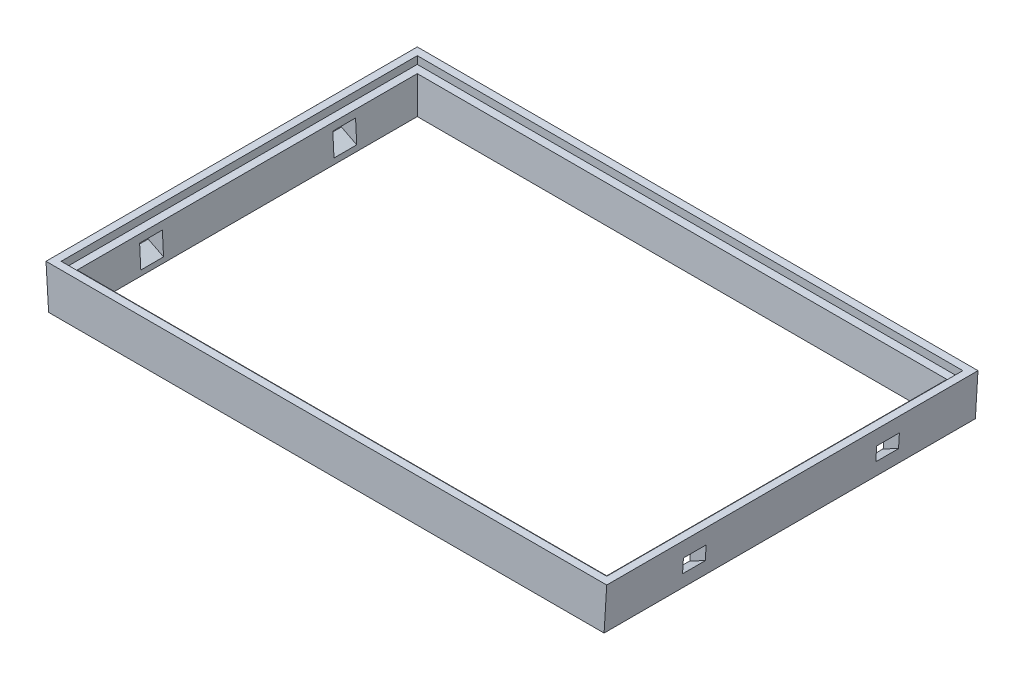
from build123d import *

# Parameters (mm, degrees)
EXTRUDE_1_DEPTH          = 49
SKETCH_2_W               = 70
SKETCH_2_H               = 45
CUT_EXTRUDE_1_DEPTH      = 55.224494
CUT_EXTRUDE_1_TAPER      = 3
SKETCH_3_W               = 72
SKETCH_3_H               = 47
CUT_EXTRUDE_2_DEPTH      = 1
SKETCH_5_W               = 3
SKETCH_5_H               = 3
CUT_EXTRUDE_3_DEPTH      = 2
EXTRUDE_2_DEPTH          = 3
EXTRUDE_3_DEPTH          = 3
SKETCH_9_W               = 92.207980396
SKETCH_9_H               = 62.219536403
CUT_EXTRUDE_4_DEPTH      = 20
CUT_EXTRUDE_4_DEPTH_BACK = 32.556614873


with BuildPart() as part:
    # Sketch 1 → Extrude 1 (new body)
    with BuildSketch(Plane.XY):
        Polygon((16.715993843, 25.667879294), (20.215993843, -31.556614873), (87.215993843, -31.556614873), (90.715993843, 25.667879294), align=None)
    extrude(amount=EXTRUDE_1_DEPTH)

    # Sketch 2 → Cut-Extrude 1 (cut)
    with BuildSketch(Plane(origin=(0, 25.667879294, 0), x_dir=(1, 0, 0), z_dir=(0, 1, 0))):
        with Locations((53.715993843, -24.5)):
            Rectangle(SKETCH_2_W, SKETCH_2_H)
    extrude(amount=-CUT_EXTRUDE_1_DEPTH, taper=CUT_EXTRUDE_1_TAPER, mode=Mode.SUBTRACT)

    # Sketch 3 → Cut-Extrude 2 (cut)
    with BuildSketch(Plane(origin=(0, 25.667879294, 0), x_dir=(1, 0, 0), z_dir=(0, 1, 0))):
        with Locations((53.715993843, -24.5)):
            Rectangle(SKETCH_3_W, SKETCH_3_H)
    extrude(amount=-CUT_EXTRUDE_2_DEPTH, mode=Mode.SUBTRACT)

    # Sketch 5 → Cut-Extrude 3 (cut)
    with BuildSketch(Plane(origin=(20.006241746, 1.048482702, 0), x_dir=(0, 0, -1), z_dir=(0.998629535, 0.052335956, 0))):
        with Locations((-37.25, 21.151810576)):
            Rectangle(SKETCH_5_W, SKETCH_5_H)
        with Locations((-11.75, 21.206889344)):
            Rectangle(SKETCH_5_W, SKETCH_5_H)
    cut_extrude_3 = extrude(amount=-CUT_EXTRUDE_3_DEPTH, mode=Mode.SUBTRACT)

    # Sketch 6 → Extrude 2 (add)
    with BuildSketch(Plane.XY.offset(35.75)):
        Polygon((18.977745448, 20.673361155), (16.95854549, 21.70219492), (17.027722258, 20.57116477), align=None)
    extrude_2 = extrude(amount=EXTRUDE_2_DEPTH)

    # Sketch 7 → Extrude 3 (add)
    with BuildSketch(Plane(origin=(0, 0, 13.25), x_dir=(-1, 0, 0), z_dir=(0, 0, -1))):
        Polygon((-18.974862848, 20.728364439), (-17.024359652, 20.626142898), (-16.955165856, 21.757451456), align=None)
    extrude_3 = extrude(amount=EXTRUDE_3_DEPTH)

    # Mirror 2: Cut-Extrude 3, Extrude 2, Extrude 3 across plane
    add(cut_extrude_3.mirror(Plane(origin=(53.715993843, 0, 0), x_dir=(0, 0, 1), z_dir=(1, 0, 0))), mode=Mode.SUBTRACT)
    add(extrude_2.mirror(Plane(origin=(53.715993843, 0, 0), x_dir=(0, 0, 1), z_dir=(1, 0, 0))))
    add(extrude_3.mirror(Plane(origin=(53.715993843, 0, 0), x_dir=(0, 0, 1), z_dir=(1, 0, 0))))

    # Sketch 9 → Cut-Extrude 4 (cut, two sides)
    with BuildSketch(Plane(origin=(0, 0, 0), x_dir=(1, 0, 0), z_dir=(0, 1, 0))) as cut_extrude_4_sk:
        with Locations((56.409215525, -25.014933301)):
            Rectangle(SKETCH_9_W, SKETCH_9_H)
    extrude(amount=CUT_EXTRUDE_4_DEPTH, mode=Mode.SUBTRACT)
    extrude(cut_extrude_4_sk.sketch, amount=-CUT_EXTRUDE_4_DEPTH_BACK, mode=Mode.SUBTRACT)


solid = part.part
